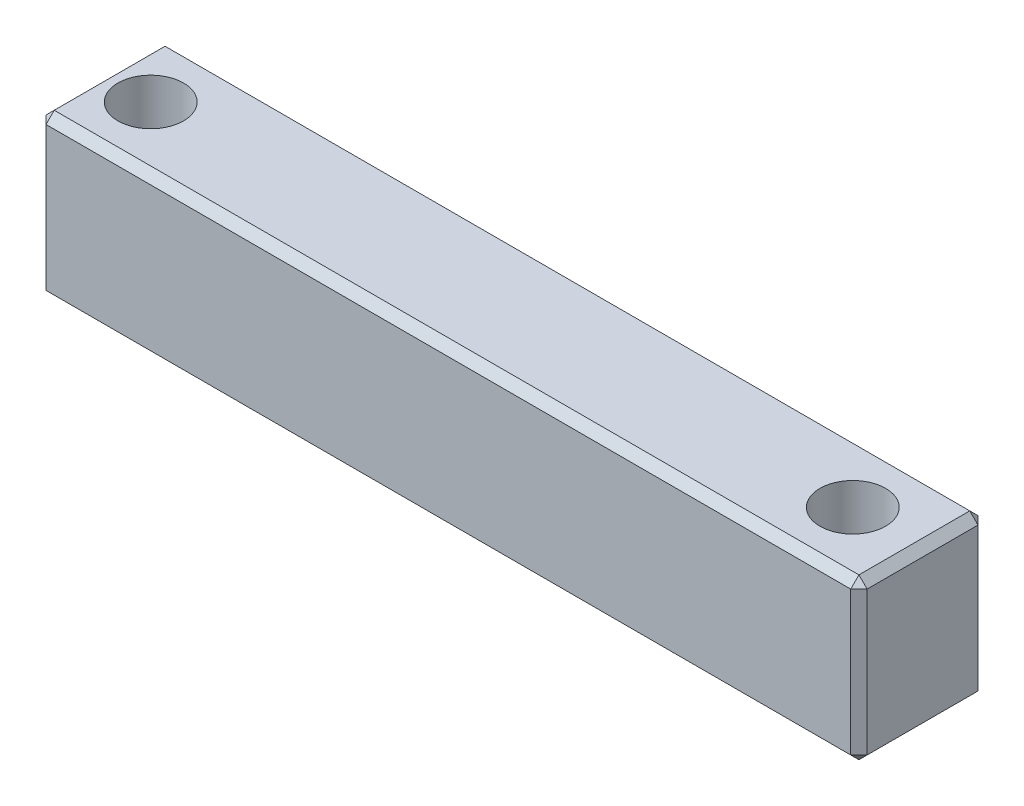
from build123d import *

# Parameters (mm, degrees)
SKETCH1_W           = 7.75
SKETCH1_H           = 9.75
BOSS_EXTRUDE1_DEPTH = 50
SKETCH4_R           = 2
CUT_EXTRUDE3_DEPTH  = 9.75
CHAMFER1_SIZE       = 0.5


with BuildPart() as part:
    # Sketch1 → Boss-Extrude1 (new body)
    with BuildSketch(Plane(origin=(0, 0, 0), x_dir=(0, 0, -1), z_dir=(1, 0, 0))):
        with Locations((3.875, 4.875)):
            Rectangle(SKETCH1_W, SKETCH1_H)
    extrude(amount=BOSS_EXTRUDE1_DEPTH)

    # Sketch4 → Cut-Extrude3 (cut)
    with BuildSketch(Plane(origin=(0, 9.75, 0), x_dir=(1, 0, 0), z_dir=(0, 1, 0))):
        with Locations((3, 3.875)):
            Circle(SKETCH4_R)
        with Locations((45.75, 3.875)):
            Circle(SKETCH4_R)
    extrude(amount=-CUT_EXTRUDE3_DEPTH, mode=Mode.SUBTRACT)

    # Chamfer1
    chamfer1_edges = [part.edges().sort_by_distance(p)[0] for p in [
        (50, 4.875, -7.75),
        (50, 9.75, -3.875),
        (50, 4.875, 0),
        (0, 9.75, -3.875),
        (0, 4.875, -7.75),
        (0, 0, -3.875),
        (0, 4.875, 0),
        (25, 9.75, 0),
        (25, 9.75, -7.75),
        (25, 0, -7.75),
        (25, 0, 0),
        (50, 0, -3.875),
    ]]
    chamfer(chamfer1_edges, length=CHAMFER1_SIZE)


solid = part.part
